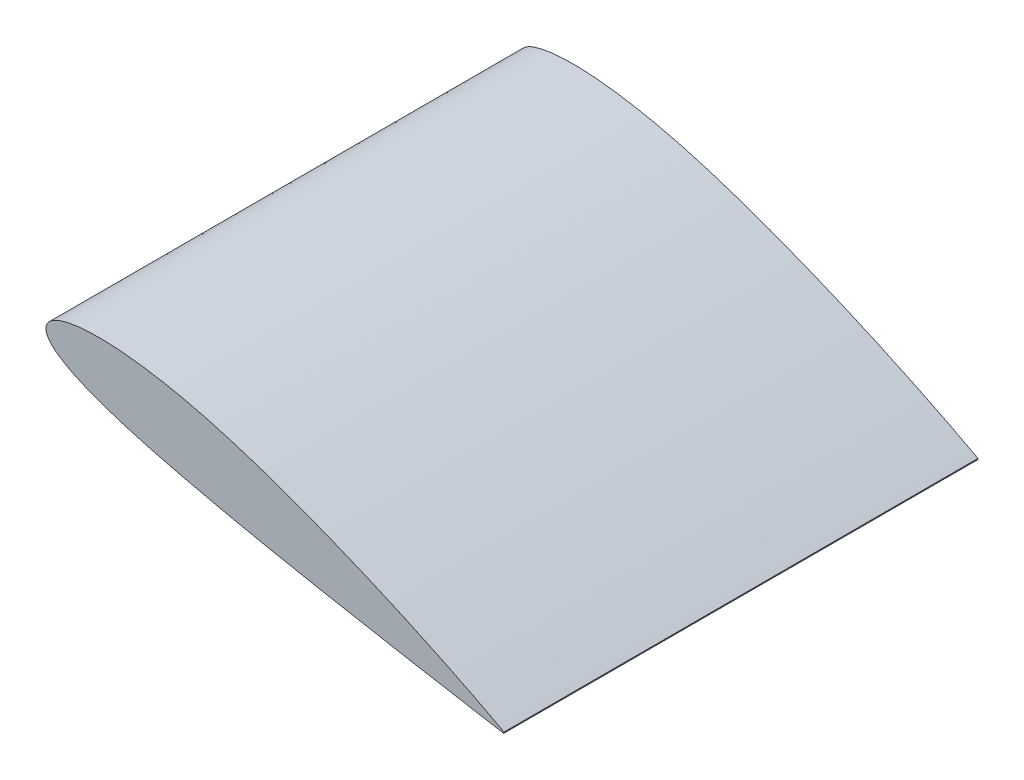
from build123d import *

# Parameters (mm, degrees)
DODANIE_WYCI_GNI_CIE1_DEPTH = 500


with BuildPart() as part:
    # Szkic1 → Dodanie-wyciągnięcie1 (new body)
    with BuildSketch(Plane.XY):
        with BuildLine():
            Line((483.153145143, -128.699567069), (482.772681146, -130.119478034))
            add(Edge.make_bspline(
                [(483.153145143, -128.699567069), (482.760443043, -128.485001292), (481.152201149, -127.606285155), (477.497476605, -125.691079144), (471.441257264, -122.489744921), (463.026613018, -118.115099432), (452.345106784, -112.629975814), (433.897381536, -103.34938471), (406.102946731, -89.836560079), (367.792917608, -72.163335302), (332.096912655, -56.716030035), (301.24347568, -44.120407754), (277.008835325, -34.644617391), (252.354053994, -25.501951622), (227.542541226, -16.821696955), (202.765846229, -8.723827759), (178.25164671, -1.47741831), (154.260209483, 4.724569681), (131.152862772, 9.800326319), (109.203104562, 13.693944863), (88.677993542, 16.403786433), (69.823321482, 17.914857051), (52.87154259, 18.298847572), (38.02425364, 17.602266542), (25.44612396, 15.927878686), (15.244890269, 13.353416473), (7.476948169, 9.939794376), (2.080106411, 5.603394229), (-0.517224741, 0.083505309), (0.181692292, -5.965342642), (3.848965329, -11.794015129), (9.985102046, -17.532623272), (18.56388353, -23.346059171), (29.537764716, -29.208404016), (42.808276784, -35.079404544), (58.230336829, -40.927060044), (75.643724775, -46.707480904), (94.857009699, -52.403973962), (115.660864854, -58.020639576), (137.83275448, -63.54928417), (161.129716809, -69.018201723), (185.370085368, -74.469559734), (210.30060466, -79.878397171), (235.679074389, -85.089825082), (261.13919178, -90.115282822), (294.393026282, -96.509376644), (334.044798347, -103.866441711), (371.975536309, -110.753455364), (405.181960714, -116.677571394), (428.210314959, -120.749589008), (448.480685073, -124.262483982), (460.285689024, -126.300919483), (469.618381045, -127.8901977), (476.362783692, -129.039750959), (480.462154436, -129.717713097), (482.299488427, -130.037197122), (482.772681146, -130.119478034)],
                knots=[0, 0, 0, 0, 0.001308371, 0.005358201, 0.012063409, 0.021337301, 0.033086619, 0.047170643, 0.081714352, 0.123442225, 0.17051687, 0.195424313, 0.220875125, 0.246594093, 0.272301831, 0.297725323, 0.322799376, 0.347028843, 0.370161527, 0.391953614, 0.412187726, 0.430670139, 0.447230521, 0.461731545, 0.474085212, 0.484275747, 0.492391839, 0.498749378, 0.504100298, 0.509453028, 0.515789797, 0.523837666, 0.533884867, 0.546005347, 0.560170802, 0.576284399, 0.594211191, 0.613803379, 0.634869304, 0.657209967, 0.680611019, 0.704834652, 0.729852897, 0.755196951, 0.780582678, 0.805728554, 0.854204497, 0.898493683, 0.918442716, 0.95282566, 0.966867904, 0.978592199, 0.987851654, 0.994547444, 0.998595732, 1, 1, 1, 1], degree=3))
        make_face()
    extrude(amount=DODANIE_WYCI_GNI_CIE1_DEPTH)


solid = part.part
